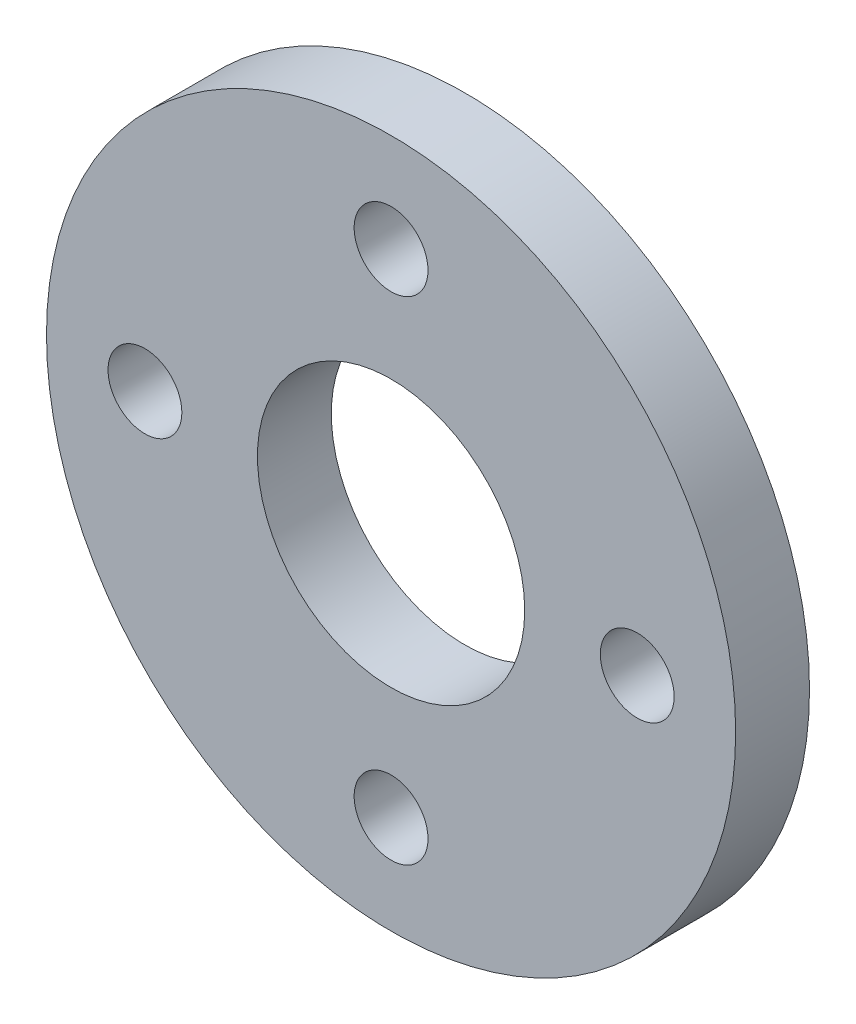
from build123d import *

# Parameters (mm, degrees)
SKETCH1_R           = 355.6
SKETCH1_R_2         = 137.912831168
SKETCH1_R_3         = 38.1
BOSS_EXTRUDE1_DEPTH = 76.2


with BuildPart() as part:
    # Sketch1 → Boss-Extrude1 (new body)
    with BuildSketch(Plane.XY):
        Circle(SKETCH1_R)
        Circle(SKETCH1_R_2, mode=Mode.SUBTRACT)
        with Locations((0, 254)):
            Circle(SKETCH1_R_3, mode=Mode.SUBTRACT)
        with Locations((254, 0)):
            Circle(SKETCH1_R_3, mode=Mode.SUBTRACT)
        with Locations((0, -254)):
            Circle(SKETCH1_R_3, mode=Mode.SUBTRACT)
        with Locations((-254, 0)):
            Circle(SKETCH1_R_3, mode=Mode.SUBTRACT)
    extrude(amount=BOSS_EXTRUDE1_DEPTH)


solid = part.part
